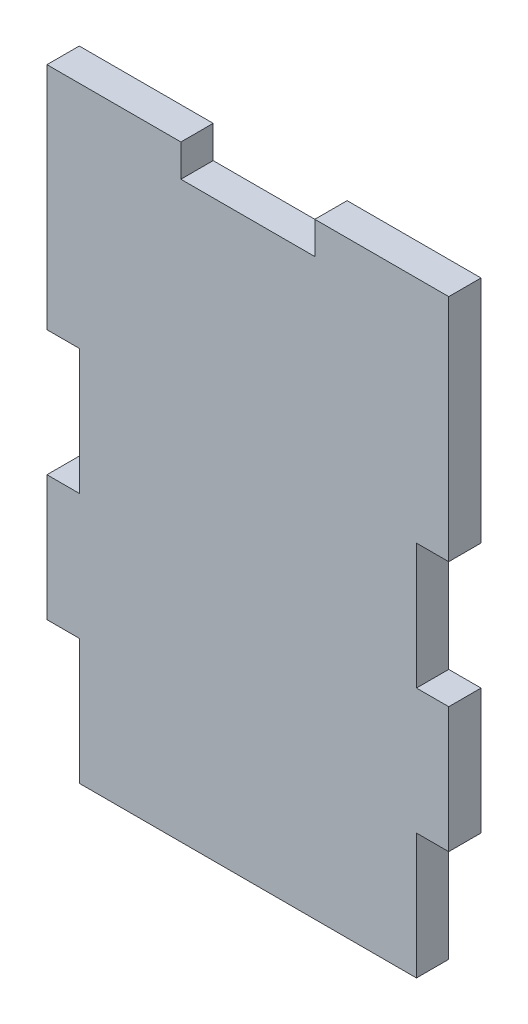
from build123d import *

# Parameters (mm, degrees)
SKETCH1_W           = 2.25
SKETCH1_H           = 13.75
SKETCH1_W_2         = 23.5
SKETCH1_H_2         = 40
SKETCH1_H_3         = 8.75
BOSS_EXTRUDE1_DEPTH = 2.25


with BuildPart() as part:
    # Sketch1 → Boss-Extrude1 (new body)
    with BuildSketch(Plane.XY):
        Polygon((-2.25, 40), (0, 40), (7.083333333, 40), (7.083333333, 42.25), (-2.25, 42.25), align=None)
        with Locations((-1.125, 33.125)):
            Rectangle(SKETCH1_W, SKETCH1_H)
        with Locations((11.75, 20)):
            Rectangle(SKETCH1_W_2, SKETCH1_H_2)
        with Locations((24.625, 33.125)):
            Rectangle(SKETCH1_W, SKETCH1_H)
        Polygon((16.416666667, 40), (23.5, 40), (25.75, 40), (25.75, 42.25), (16.416666667, 42.25), align=None)
        with Locations((24.625, 13.125)):
            Rectangle(SKETCH1_W, SKETCH1_H_3)
        with Locations((-1.125, 13.125)):
            Rectangle(SKETCH1_W, SKETCH1_H_3)
    extrude(amount=BOSS_EXTRUDE1_DEPTH)


solid = part.part
